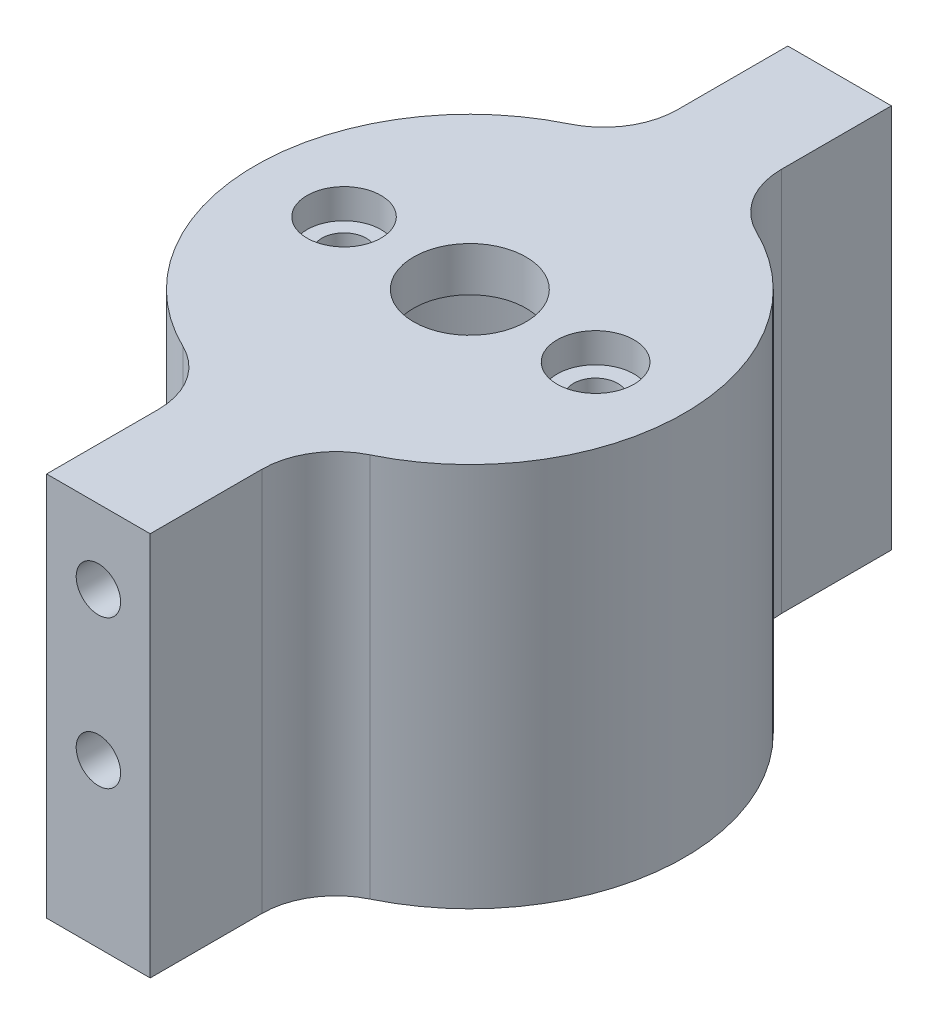
from build123d import *

# Parameters (mm, degrees)
SKETCH1_R           = 14.5
BOSS_EXTRUDE1_DEPTH = 2
SKETCH2_R           = 3.8
SKETCH2_R_2         = 1.5
CUT_EXTRUDE1_DEPTH  = 2.5
SKETCH3_R           = 14.5
SKETCH3_R_2         = 12.5
BOSS_EXTRUDE2_DEPTH = 23
SKETCH4_R           = 14.5
SKETCH4_R_2         = 3.8
SKETCH4_R_3         = 1.5
BOSS_EXTRUDE3_DEPTH = 1
SKETCH5_R           = 2.6
SKETCH5_R_2         = 2.5
CUT_EXTRUDE2_DEPTH  = 2
BOSS_EXTRUDE4_DEPTH = 26
SKETCH14_W          = 7
SKETCH14_H          = 26
CUT_EXTRUDE3_DEPTH  = 0.11
SKETCH16_R          = 1.5
CUT_EXTRUDE4_DEPTH  = 6
BOSS_EXTRUDE5_DEPTH = 26
SKETCH19_R          = 1.5
CUT_EXTRUDE5_DEPTH  = 5
FILLET1_R           = 5


with BuildPart() as part:
    # Sketch1 → Boss-Extrude1 (new body)
    with BuildSketch(Plane(origin=(0, 0, 0), x_dir=(1, 0, 0), z_dir=(0, 1, 0))):
        Circle(SKETCH1_R)
    extrude(amount=BOSS_EXTRUDE1_DEPTH)

    # Sketch2 → Cut-Extrude1 (cut)
    with BuildSketch(Plane(origin=(0, 2, 0), x_dir=(1, 0, 0), z_dir=(0, 1, 0))):
        Circle(SKETCH2_R)
        with Locations((-8.5, 0)):
            Circle(SKETCH2_R_2)
        with Locations((8.5, 0)):
            Circle(SKETCH2_R_2)
    extrude(amount=-CUT_EXTRUDE1_DEPTH, mode=Mode.SUBTRACT)

    # Sketch3 → Boss-Extrude2 (add)
    with BuildSketch(Plane.XZ):
        Circle(SKETCH3_R)
        Circle(SKETCH3_R_2, mode=Mode.SUBTRACT)
    extrude(amount=BOSS_EXTRUDE2_DEPTH)

    # Sketch4 → Boss-Extrude3 (add)
    with BuildSketch(Plane(origin=(0, 2, 0), x_dir=(1, 0, 0), z_dir=(0, 1, 0))):
        Circle(SKETCH4_R)
        Circle(SKETCH4_R_2, mode=Mode.SUBTRACT)
        with Locations((8.5, 0)):
            Circle(SKETCH4_R_3, mode=Mode.SUBTRACT)
        with Locations((-8.5, 0)):
            Circle(SKETCH4_R_3, mode=Mode.SUBTRACT)
    extrude(amount=BOSS_EXTRUDE3_DEPTH)

    # Sketch5 → Cut-Extrude2 (cut)
    with BuildSketch(Plane(origin=(0, 3, 0), x_dir=(1, 0, 0), z_dir=(0, 1, 0))):
        with Locations((8.5, 0)):
            Circle(SKETCH5_R)
        with Locations((-8.5, 0)):
            Circle(SKETCH5_R_2)
    extrude(amount=-CUT_EXTRUDE2_DEPTH, mode=Mode.SUBTRACT)

    # Sketch12 → Boss-Extrude4 (add)
    with BuildSketch(Plane.XZ.offset(23)):
        with BuildLine():
            Line((3.5, -25.1), (-3.5, -25.1))
            Line((-3.5, -25.1), (-3.5, -14.071247279))
            ThreePointArc((-3.5, -14.071247279), (0, -14.5), (3.5, -14.071247279))
            Line((3.5, -14.071247279), (3.5, -25.1))
        make_face()
    extrude(amount=-BOSS_EXTRUDE4_DEPTH)

    # Sketch14 → Cut-Extrude3 (cut)
    with BuildSketch(Plane(origin=(0, 0, -25.1), x_dir=(-1, 0, 0), z_dir=(0, 0, -1))):
        with Locations((0, -10)):
            Rectangle(SKETCH14_W, SKETCH14_H)
    extrude(amount=-CUT_EXTRUDE3_DEPTH, mode=Mode.SUBTRACT)

    # Sketch16 → Cut-Extrude4 (cut)
    with BuildSketch(Plane(origin=(0, 0, -24.99), x_dir=(-1, 0, 0), z_dir=(0, 0, -1))):
        with Locations((0, -2)):
            Circle(SKETCH16_R)
        with Locations((0, -12)):
            Circle(SKETCH16_R)
    extrude(amount=-CUT_EXTRUDE4_DEPTH, mode=Mode.SUBTRACT)

    # Sketch18 → Boss-Extrude5 (add, through all)
    with BuildSketch(Plane.XZ.offset(23)):
        with BuildLine():
            Line((3.5, 25.1), (-3.5, 25.1))
            Line((-3.5, 25.1), (-3.5, 14.071247279))
            ThreePointArc((-3.5, 14.071247279), (0, 14.5), (3.5, 14.071247279))
            Line((3.5, 14.071247279), (3.5, 25.1))
        make_face()
    extrude(amount=-BOSS_EXTRUDE5_DEPTH)

    # Sketch19 → Cut-Extrude5 (cut)
    with BuildSketch(Plane.XY.offset(25.1)):
        with Locations((0, -2)):
            Circle(SKETCH19_R)
        with Locations((0, -12)):
            Circle(SKETCH19_R)
    extrude(amount=-CUT_EXTRUDE5_DEPTH, mode=Mode.SUBTRACT)

    # Fillet1
    fillet1_edges = [part.edges().sort_by_distance(p)[0] for p in [
        (-3.5, -10, -14.071247279),
        (3.5, -10, -14.071247279),
        (3.5, -10, 14.071247279),
        (-3.5, -10, 14.071247279),
    ]]
    fillet(fillet1_edges, radius=FILLET1_R)


solid = part.part
